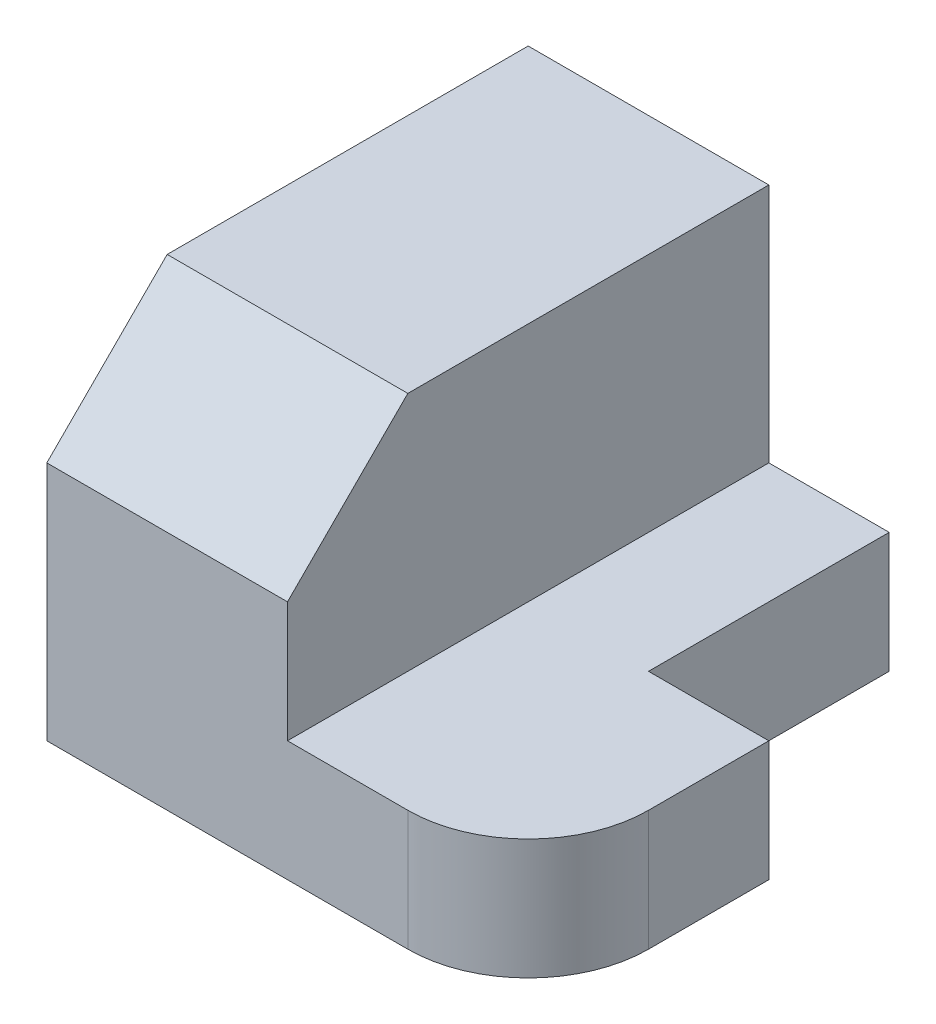
from build123d import *

# Parameters (mm, degrees)
EXTRUDE_1_DEPTH     = 5
SKETCH_1_3_W        = 10
SKETCH_1_3_H        = 20
EXTRUDE_2_DEPTH     = 15
CUT_EXTRUDE_1_DEPTH = 15
SCALE_1_SCALE       = 0.2


with BuildPart() as part:
    # 草圖1 → 填料-伸長1 (new body)
    with BuildSketch(Plane(origin=(0, 0, 0), x_dir=(1, 0, 0), z_dir=(0, 1, 0))):
        with BuildLine():
            Line((10, 10), (5, 10))
            Line((5, 10), (5, -5))
            Line((5, -5), (5, -10))
            Line((5, -10), (10, -10))
            ThreePointArc((10, -10), (13.535533906, -8.535533906), (15, -5))
            Line((15, -5), (15, 0))
            Line((15, 0), (10, 0))
            Line((10, 0), (10, 10))
        make_face()
    extrude(amount=EXTRUDE_1_DEPTH)

    # 草圖1<3> → 填料-伸長2 (add)
    with BuildSketch(Plane(origin=(0, 0, 0), x_dir=(1, 0, 0), z_dir=(0, 1, 0))):
        Rectangle(SKETCH_1_3_W, SKETCH_1_3_H)
    extrude(amount=EXTRUDE_2_DEPTH)

    # 草圖2 → 除料-伸長1 (cut)
    with BuildSketch(Plane.ZY.offset(5)):
        Polygon((5, 15), (10, 10), (10, 15), align=None)
    extrude(amount=-CUT_EXTRUDE_1_DEPTH, mode=Mode.SUBTRACT)


with BuildPart() as part_1:
    # 縮放比例1: scaled about (1.80718877, 6.292432053, -0.0083263)
    add(part.part.scale(SCALE_1_SCALE).moved(Location((1.445751016, 5.033945642, -0.00666104))))


solid = part_1.part
